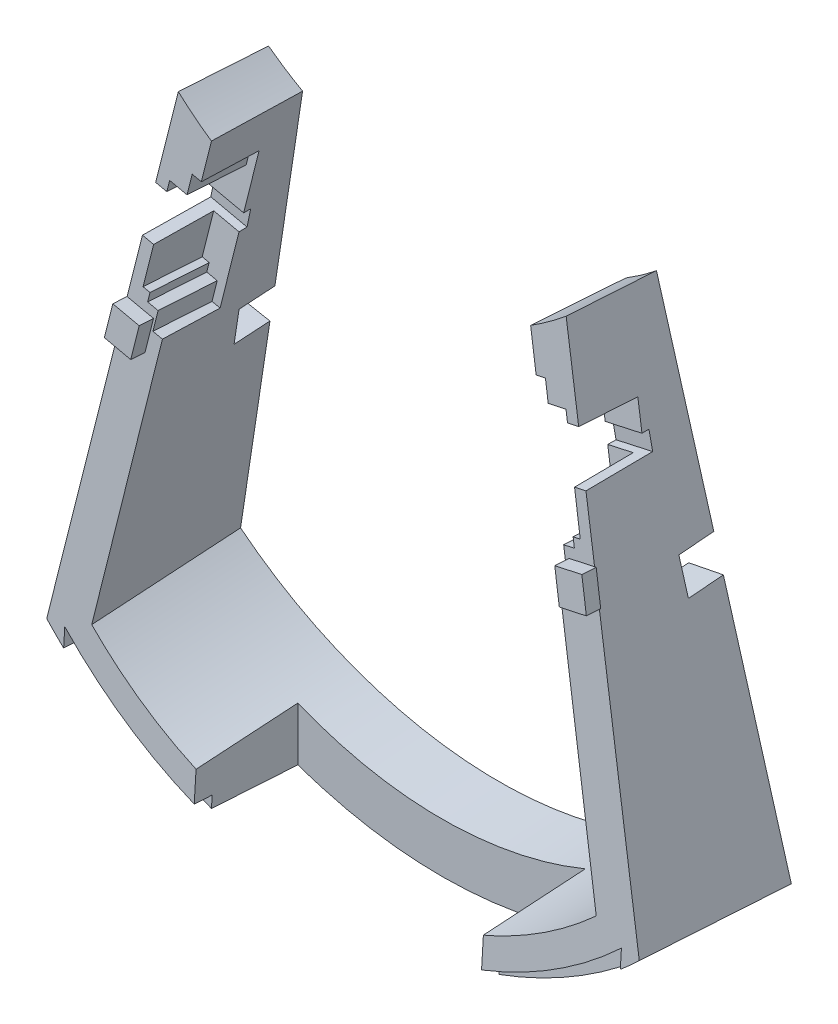
from build123d import *

# Parameters (mm, degrees)
BOSS_EXTRUDE1_DEPTH     = 209.55
SKETCH3_W               = 240.510539239
SKETCH3_H               = 265.315522901
CUT_EXTRUDE1_DEPTH      = 61.780833862
CUT_EXTRUDE2_DEPTH      = 59.88645018
CUT_EXTRUDE3_DEPTH      = 12.7
CUT_EXTRUDE4_DEPTH      = 6.35
SKETCH7_W               = 101.6
SKETCH7_H               = 37.465
CUT_EXTRUDE5_DEPTH      = 178.176697197
CUT_EXTRUDE5_DEPTH_BACK = 42.974613266
SKETCH10_R              = 2.667
CUT_EXTRUDE8_DEPTH      = 50.8
SKETCH11_R              = 2.667
CUT_EXTRUDE9_DEPTH      = 50.8
BOSS_EXTRUDE2_DEPTH     = 5.08
CUT_EXTRUDE10_DEPTH     = 19.05
CUT_EXTRUDE11_DEPTH     = 19.05
CUT_EXTRUDE12_DEPTH     = 20.955


with BuildPart() as part:
    # Sketch2 → Boss-Extrude1 (new body)
    with BuildSketch(Plane(origin=(0, 0, 0), x_dir=(0, 0, -1), z_dir=(1, 0, 0))):
        Polygon((-42.945985173, 177.447146824), (-53.974998987, -0.010456153), (-57.520039142, -57.050399967), (3.378068797, -53.539609111), (0, 0), (-11.195985173, 177.447146824), align=None)
    extrude(amount=BOSS_EXTRUDE1_DEPTH)

    # Sketch3 → Cut-Extrude1 (cut, through all)
    with BuildSketch(Plane(origin=(0, 3.341605618, 53.766667899), x_dir=(1, 0, 0), z_dir=(0, 0.062030449, 0.998074257))):
        with Locations((107.411926899, 58.645471754)):
            Rectangle(SKETCH3_W, SKETCH3_H)
        with BuildLine():
            Line((172.901684058, 173.982013262), (209.55, 0))
            ThreePointArc((209.55, 0), (104.775, -41.729500882), (0, 0))
            Line((0, 0), (35.741813567, 174.170499118))
            ThreePointArc((35.741813567, 174.170499118), (104.287966167, 149.492856038), (172.901684058, 173.982013262))
        make_face(mode=Mode.SUBTRACT)
    extrude(amount=-CUT_EXTRUDE1_DEPTH, mode=Mode.SUBTRACT)

    # Sketch4 → Cut-Extrude2 (cut, through all)
    with BuildSketch(Plane(origin=(0, 0, 0), x_dir=(-1, 0, 0), z_dir=(0, 0.062969545, -0.998015449))):
        with BuildLine():
            Line((-160.868955232, 170.846287594), (-193.979445404, 12.421844718))
            ThreePointArc((-193.979445404, 12.421844718), (-104.775, -21.808079515), (-15.570554596, 12.421844718))
            Line((-15.570554596, 12.421844718), (-48.003667802, 170.846287594))
            Line((-48.003667802, 170.846287594), (-160.868955232, 170.846287594))
        make_face()
    extrude(amount=-CUT_EXTRUDE2_DEPTH, mode=Mode.SUBTRACT)

    # Sketch5 → Cut-Extrude3 (cut)
    with BuildSketch(Plane(origin=(0, 0, 0), x_dir=(-1, 0, 0), z_dir=(0, 0.062969545, -0.998015449))):
        Polygon((-189.575592117, 100.998599654), (-176.057501646, 98.17333738), (-178.65564658, 85.741939916), (-192.173737051, 88.56720219), align=None)
        Polygon((-33.125849843, 98.17333738), (-19.492211444, 100.964455529), (-16.94721956, 88.533058065), (-30.58085796, 85.741939916), align=None)
    extrude(amount=-CUT_EXTRUDE3_DEPTH, mode=Mode.SUBTRACT)

    # Sketch6 → Cut-Extrude4 (cut)
    with BuildSketch(Plane(origin=(0, 3.341605618, 53.766667899), x_dir=(1, 0, 0), z_dir=(0, 0.062030449, 0.998074257))):
        with BuildLine():
            Line((6.35, -5.683612864), (6.35, 0.666387136))
            ThreePointArc((6.35, 0.666387136), (104.775, -38.257263578), (203.2, 0.666387136))
            Line((203.2, 0.666387136), (203.2, -5.683612864))
            ThreePointArc((203.2, -5.683612864), (104.775, -41.729500882), (6.35, -5.683612864))
        make_face()
    extrude(amount=-CUT_EXTRUDE4_DEPTH, mode=Mode.SUBTRACT)

    # Sketch7 → Cut-Extrude5 (cut, two sides)
    with BuildSketch(Plane(origin=(0, 0, 0), x_dir=(1, 0, 0), z_dir=(0, 1, 0))) as cut_extrude5_sk:
        with Locations((104.775, -37.622667571)):
            Rectangle(SKETCH7_W, SKETCH7_H)
    extrude(amount=CUT_EXTRUDE5_DEPTH, mode=Mode.SUBTRACT)
    extrude(cut_extrude5_sk.sketch, amount=-CUT_EXTRUDE5_DEPTH_BACK, mode=Mode.SUBTRACT)

    # Sketch10 → Cut-Extrude8 (cut)
    with BuildSketch(Plane(origin=(200.647085604, 42.183769093, -2.621726904), x_dir=(-0.012512246, -0.002630558, -0.999918259), z_dir=(0.978526509, 0.205724076, -0.012785779))):
        with Locations(Location((-34.774476568, 102.235809265, 0), (0, 0, 90))):  # turned: the seam where the file's is
            Circle(SKETCH10_R)
    extrude(amount=-CUT_EXTRUDE8_DEPTH, mode=Mode.SUBTRACT)

    # Sketch11 → Cut-Extrude9 (cut)
    with BuildSketch(Plane(origin=(0, 0, 0), x_dir=(-0.012215925, 0.002502022, 0.999922253), z_dir=(-0.979586609, 0.200635456, -0.01246952))):
        with Locations(Location((32.158429543, 145.097393201, 0), (0, 0, 270))):  # turned: the seam where the file's is
            Circle(SKETCH11_R)
    extrude(amount=-CUT_EXTRUDE9_DEPTH, mode=Mode.SUBTRACT)

    # Sketch13 → Boss-Extrude2 (add)
    with BuildSketch(Plane(origin=(0, 3.341605618, 53.766667899), x_dir=(1, 0, 0), z_dir=(0, 0.062030449, 0.998074257))):
        Polygon((21.844, 106.446204126), (19.546311985, 95.249529182), (29.001281937, 93.309259303), (31.298969952, 104.505934246), align=None)
        Polygon((178.251030048, 104.505934246), (187.706, 106.446204126), (190.003688015, 95.249529182), (180.548718063, 93.309259303), align=None)
    extrude(amount=BOSS_EXTRUDE2_DEPTH)

    # Sketch14 → Cut-Extrude10 (cut)
    with BuildSketch(Plane(origin=(0, 0, 0), x_dir=(-0.012215925, 0.002502022, 0.999922253), z_dir=(-0.979586609, 0.200635456, -0.01246952))):
        Polygon((45.523011798, 138.747393201), (45.909608937, 132.397393201), (22.028011798, 132.397393201), (22.028011798, 138.747393201), align=None)
    extrude(amount=-CUT_EXTRUDE10_DEPTH, mode=Mode.SUBTRACT)

    # Sketch15 → Cut-Extrude11 (cut)
    with BuildSketch(Plane(origin=(200.647085604, 42.183769093, -2.621726904), x_dir=(-0.012512246, -0.002630558, -0.999918259), z_dir=(0.978526509, 0.205724076, -0.012785779))):
        Polygon((-48.138588614, 95.885809265), (-24.643588614, 95.885809265), (-24.643588614, 89.535809265), (-48.52476738, 89.535809265), align=None)
    extrude(amount=-CUT_EXTRUDE11_DEPTH, mode=Mode.SUBTRACT)

    # Sketch16 → Cut-Extrude12 (cut)
    with BuildSketch(Plane(origin=(0, 3.341605618, 53.766667899), x_dir=(1, 0, 0), z_dir=(0, 0.062030449, 0.998074257))):
        Polygon((45.273381068, 151.976469085), (41.976582335, 152.653010556), (40.572439659, 145.81059809), (34.352064691, 147.087091432), (33.586168686, 143.354866451), (29.586519575, 144.175641), (27.283705248, 132.953985446), (31.283354359, 132.133210897), (27.13987731, 111.94197286), (29.628027298, 111.431375523), (28.988403038, 108.314475026), (32.720628019, 107.548579021), (31.316485344, 100.706166555), (34.718800408, 100.015076365), align=None)
        Polygon((174.153822626, 100.015076365), (163.599241965, 151.976469085), (166.896040699, 152.653010556), (168.300183374, 145.81059809), (174.520558343, 147.087091432), (175.286454348, 143.354866451), (179.286103459, 144.175641), (181.588917786, 132.953985446), (177.589268675, 132.133210897), (181.732745723, 111.94197286), (179.244595736, 111.431375523), (179.884219995, 108.314475026), (176.151995014, 107.548579021), (177.55613769, 100.706166555), align=None)
    extrude(amount=-CUT_EXTRUDE12_DEPTH, mode=Mode.SUBTRACT)


solid = part.part
